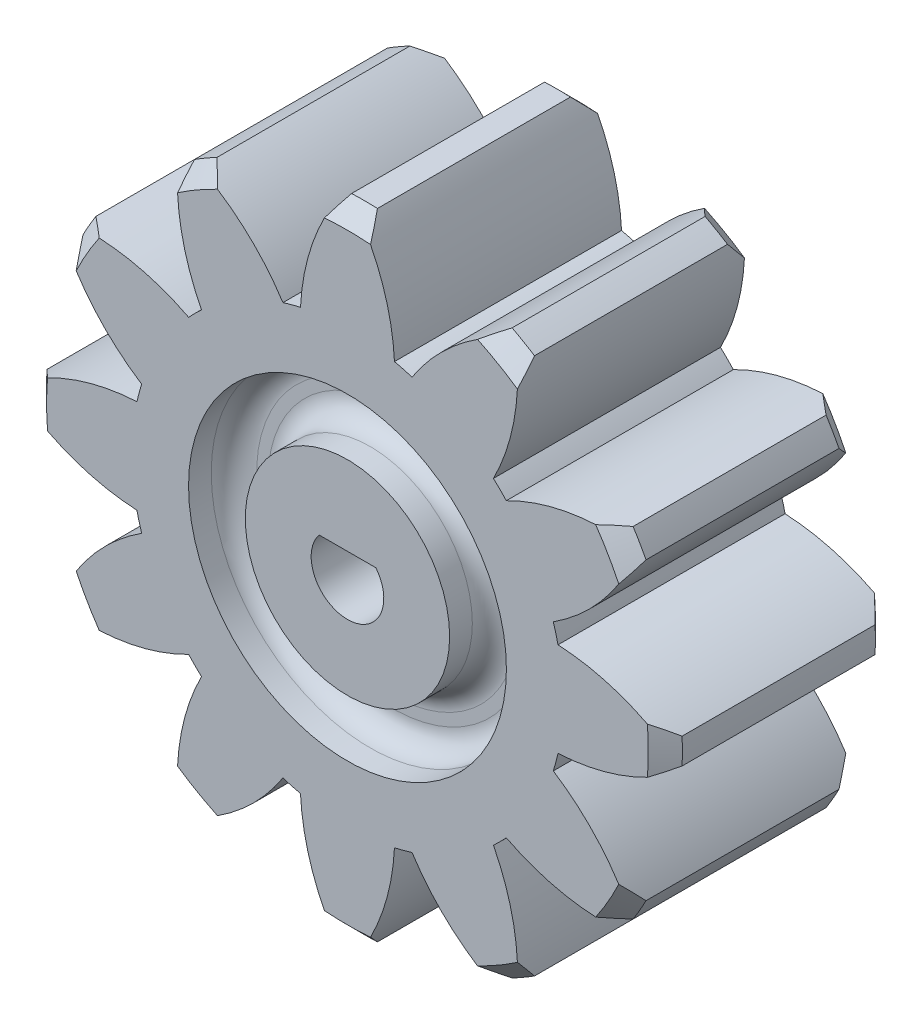
from build123d import *

# Parameters (mm, degrees)
SKETCH1_R                    = 9.5
BOSS_EXTRUDE1_DEPTH          = 10
CHAMFER1_SIZE                = 0.75
CIRPATTERN1_COUNT            = 12
CHAMFER1_OF_CIRPATTERN1_SIZE = 0.75
SKETCH2_R                    = 7
SKETCH2_R_2                  = 4.5
CUT_EXTRUDE1_DEPTH           = 2
FILLET1_R                    = 1
FILLET1_OF_MIRROR1_R         = 1
CUT_EXTRUDE2_REACH           = 12


with BuildPart() as part:
    # Sketch1 → Boss-Extrude1 (new body)
    with BuildSketch(Plane.XY):
        Circle(SKETCH1_R)
        with BuildLine():
            ThreePointArc((-2.07, 9.271736623), (0, 9.5), (2.07, 9.271736623))
            ThreePointArc((2.07, 9.271736623), (1.625653209, 11.72726856), (0.57, 13.988391616))
            ThreePointArc((0.57, 13.988391616), (0, 14), (-0.57, 13.988391616))
            ThreePointArc((-0.57, 13.988391616), (-1.625653209, 11.72726856), (-2.07, 9.271736623))
        make_face()
    boss_extrude1 = extrude(amount=BOSS_EXTRUDE1_DEPTH)

    # Chamfer1
    chamfer1_edges = [part.edges().sort_by_distance(p)[0] for p in [
        (0, 14, 10),
        (0, 14, 0),
    ]]
    chamfer(chamfer1_edges, length=CHAMFER1_SIZE)

    # CirPattern1: Boss-Extrude1 ×12 about axis
    cirpattern1_axis = Axis((0, 0, 0), (0, 0, 1))
    for i in range(1, CIRPATTERN1_COUNT):
        add(boss_extrude1.rotate(cirpattern1_axis, i * 360 / CIRPATTERN1_COUNT))

    # Chamfer1 of CirPattern1
    chamfer1_of_cirpattern1_edges = [part.edges().sort_by_distance(p)[0] for p in [
        (-7, 12.124355653, 10),
        (-7, 12.124355653, 0),
        (-12.124355653, 7, 10),
        (-12.124355653, 7, 0),
        (-14, 0, 10),
        (-14, 0, 0),
        (-12.124355653, -7, 10),
        (-12.124355653, -7, 0),
        (-7, -12.124355653, 10),
        (-7, -12.124355653, 0),
        (0, -14, 10),
        (0, -14, 0),
        (7, -12.124355653, 10),
        (7, -12.124355653, 0),
        (12.124355653, -7, 10),
        (12.124355653, -7, 0),
        (14, 0, 10),
        (14, 0, 0),
        (12.124355653, 7, 10),
        (12.124355653, 7, 0),
        (7, 12.124355653, 10),
        (7, 12.124355653, 0),
    ]]
    chamfer(chamfer1_of_cirpattern1_edges, length=CHAMFER1_OF_CIRPATTERN1_SIZE)

    # Sketch2 → Cut-Extrude1 (cut)
    with BuildSketch(Plane.XY.offset(10)):
        Circle(SKETCH2_R)
        Circle(SKETCH2_R_2, mode=Mode.SUBTRACT)
    cut_extrude1 = extrude(amount=-CUT_EXTRUDE1_DEPTH, mode=Mode.SUBTRACT)

    # Fillet1
    fillet1_edges = [part.edges().sort_by_distance(p)[0] for p in [
        (-7, 0, 8),
        (-4.5, 0, 8),
    ]]
    fillet(fillet1_edges, radius=FILLET1_R)

    # Mirror1: Cut-Extrude1 across plane
    add(cut_extrude1.mirror(Plane.XY.offset(5)), mode=Mode.SUBTRACT)

    # Fillet1 of Mirror1
    fillet1_of_mirror1_edges = [part.edges().sort_by_distance(p)[0] for p in [
        (-7, 0, 2),
        (-4.5, 0, 2),
    ]]
    fillet(fillet1_of_mirror1_edges, radius=FILLET1_OF_MIRROR1_R)

    # Sketch3 → Cut-Extrude2 (cut, up to next)
    with BuildSketch(Plane.XY.offset(10), mode=Mode.PRIVATE) as cut_extrude2_sk1:
        with BuildLine():
            Line((1.2489996, 1), (-1.2489996, 1))
            ThreePointArc((-1.2489996, 1), (-0.529905954, -1.509701851), (1.6, 0))
            ThreePointArc((1.6, 0), (1.509701851, 0.529905954), (1.2489996, 1))
        make_face()
    cut_extrude2_tool1 = extrude(cut_extrude2_sk1.sketch, amount=-CUT_EXTRUDE2_REACH, mode=Mode.PRIVATE) & part.part
    add(cut_extrude2_tool1.solids().sort_by_distance((0, -0.185603, 10))[0], mode=Mode.SUBTRACT)


solid = part.part
